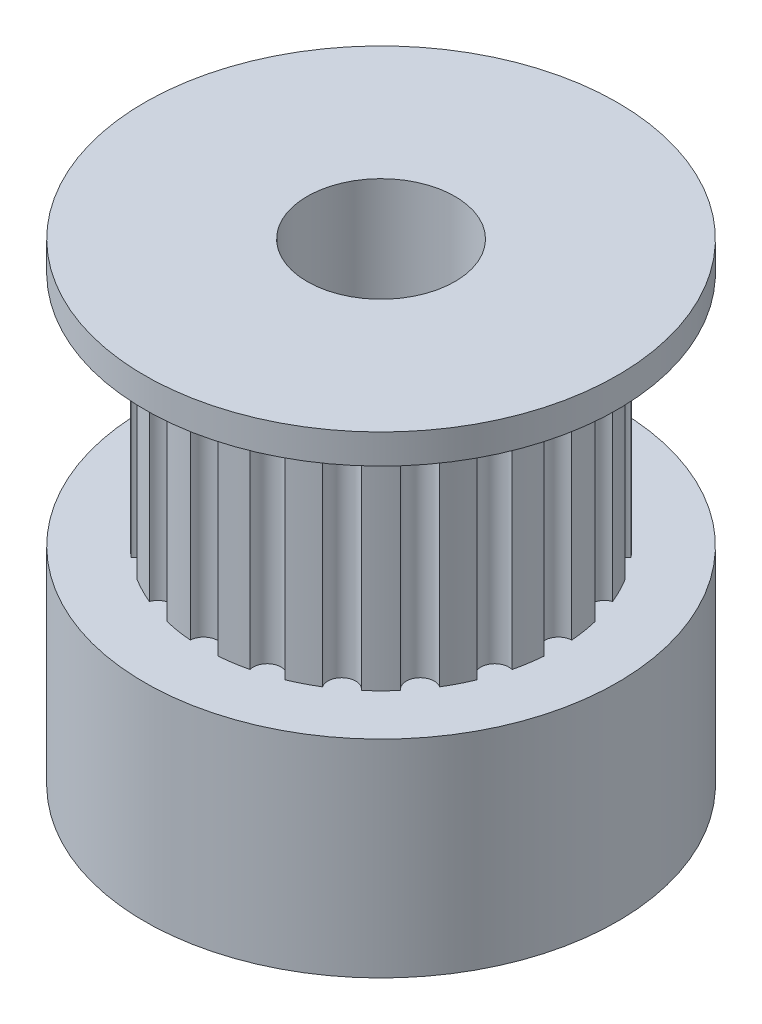
from build123d import *

# Parameters (mm, degrees)
ESQUISSE2_R             = 2.5
ENL_V_MAT_EXTRU_1_DEPTH = 17
ENL_V_MAT_EXTRU_2_DEPTH = 8


with BuildPart() as part:
    # Esquisse1 → Révolution1 (revolve)
    with BuildSketch(Plane.XY):
        Polygon((0, 0), (0, 16), (8, 16), (8, 15), (6, 15), (6, 7), (8, 7), (8, 0), align=None)
    revolve(axis=Axis((0, 0, 0), (0, 1, 0)))

    # Esquisse2 → Enlèv. mat.-Extru.1 (cut, through all)
    with BuildSketch(Plane(origin=(0, 16, 0), x_dir=(1, 0, 0), z_dir=(0, 1, 0))):
        Circle(ESQUISSE2_R)
    extrude(amount=-ENL_V_MAT_EXTRU_1_DEPTH, mode=Mode.SUBTRACT)

    # Esquisse3 → Enlèv. mat.-Extru.2 (cut)
    with BuildSketch(Plane.XZ.offset(-15)):
        with BuildLine():
            ThreePointArc((5.981504002, -0.470754574), (5.528882211, 0), (5.981504002, 0.470754574))
            ThreePointArc((5.981504002, 0.470754574), (6, 0), (5.981504002, -0.470754574))
        make_face()
        with BuildLine():
            ThreePointArc((5.543277195, -2.296100594), (5.706339098, -1.854101966), (5.834219522, -1.400672183))
            ThreePointArc((5.834219522, -1.400672183), (5.258279454, -1.708518563), (5.543277195, -2.296100594))
        make_face()
        with BuildLine():
            ThreePointArc((4.562435794, -3.89668829), (4.472959669, -3.249795425), (5.115840986, -3.134991388))
            ThreePointArc((5.115840986, -3.134991388), (4.854101966, -3.526711514), (4.562435794, -3.89668829))
        make_face()
        with BuildLine():
            ThreePointArc((3.134991388, -5.115840986), (3.249795425, -4.472959669), (3.89668829, -4.562435794))
            ThreePointArc((3.89668829, -4.562435794), (3.526711514, -4.854101966), (3.134991388, -5.115840986))
        make_face()
        with BuildLine():
            ThreePointArc((1.400672183, -5.834219522), (1.708518563, -5.258279454), (2.296100594, -5.543277195))
            ThreePointArc((2.296100594, -5.543277195), (1.854101966, -5.706339098), (1.400672183, -5.834219522))
        make_face()
        with BuildLine():
            ThreePointArc((-0.470754574, -5.981504002), (0, -5.528882211), (0.470754574, -5.981504002))
            ThreePointArc((0.470754574, -5.981504002), (0, -6), (-0.470754574, -5.981504002))
        make_face()
        with BuildLine():
            ThreePointArc((-2.296100594, -5.543277195), (-1.708518563, -5.258279454), (-1.400672183, -5.834219522))
            ThreePointArc((-1.400672183, -5.834219522), (-1.854101966, -5.706339098), (-2.296100594, -5.543277195))
        make_face()
        with BuildLine():
            ThreePointArc((-3.89668829, -4.562435794), (-3.249795425, -4.472959669), (-3.134991388, -5.115840986))
            ThreePointArc((-3.134991388, -5.115840986), (-3.526711514, -4.854101966), (-3.89668829, -4.562435794))
        make_face()
        with BuildLine():
            ThreePointArc((-5.115840986, -3.134991388), (-4.472959669, -3.249795425), (-4.562435794, -3.89668829))
            ThreePointArc((-4.562435794, -3.89668829), (-4.854101966, -3.526711514), (-5.115840986, -3.134991388))
        make_face()
        with BuildLine():
            ThreePointArc((-5.834219522, -1.400672183), (-5.258279454, -1.708518563), (-5.543277195, -2.296100594))
            ThreePointArc((-5.543277195, -2.296100594), (-5.706339098, -1.854101966), (-5.834219522, -1.400672183))
        make_face()
        with BuildLine():
            ThreePointArc((-5.981504002, 0.470754574), (-5.528882211, 0), (-5.981504002, -0.470754574))
            ThreePointArc((-5.981504002, -0.470754574), (-6, 0), (-5.981504002, 0.470754574))
        make_face()
        with BuildLine():
            ThreePointArc((-5.543277195, 2.296100594), (-5.258279454, 1.708518563), (-5.834219522, 1.400672183))
            ThreePointArc((-5.834219522, 1.400672183), (-5.706339098, 1.854101966), (-5.543277195, 2.296100594))
        make_face()
        with BuildLine():
            ThreePointArc((-4.562435794, 3.89668829), (-4.472959669, 3.249795425), (-5.115840986, 3.134991388))
            ThreePointArc((-5.115840986, 3.134991388), (-4.854101966, 3.526711514), (-4.562435794, 3.89668829))
        make_face()
        with BuildLine():
            ThreePointArc((-3.134991388, 5.115840986), (-3.249795425, 4.472959669), (-3.89668829, 4.562435794))
            ThreePointArc((-3.89668829, 4.562435794), (-3.526711514, 4.854101966), (-3.134991388, 5.115840986))
        make_face()
        with BuildLine():
            ThreePointArc((-1.400672183, 5.834219522), (-1.708518563, 5.258279454), (-2.296100594, 5.543277195))
            ThreePointArc((-2.296100594, 5.543277195), (-1.854101966, 5.706339098), (-1.400672183, 5.834219522))
        make_face()
        with BuildLine():
            ThreePointArc((0.470754574, 5.981504002), (0, 5.528882211), (-0.470754574, 5.981504002))
            ThreePointArc((-0.470754574, 5.981504002), (0, 6), (0.470754574, 5.981504002))
        make_face()
        with BuildLine():
            ThreePointArc((2.296100594, 5.543277195), (1.708518563, 5.258279454), (1.400672183, 5.834219522))
            ThreePointArc((1.400672183, 5.834219522), (1.854101966, 5.706339098), (2.296100594, 5.543277195))
        make_face()
        with BuildLine():
            ThreePointArc((3.89668829, 4.562435794), (3.249795425, 4.472959669), (3.134991388, 5.115840986))
            ThreePointArc((3.134991388, 5.115840986), (3.526711514, 4.854101966), (3.89668829, 4.562435794))
        make_face()
        with BuildLine():
            ThreePointArc((5.115840986, 3.134991388), (4.472959669, 3.249795425), (4.562435794, 3.89668829))
            ThreePointArc((4.562435794, 3.89668829), (4.854101966, 3.526711514), (5.115840986, 3.134991388))
        make_face()
        with BuildLine():
            ThreePointArc((5.834219522, 1.400672183), (5.258279454, 1.708518563), (5.543277195, 2.296100594))
            ThreePointArc((5.543277195, 2.296100594), (5.706339098, 1.854101966), (5.834219522, 1.400672183))
        make_face()
    extrude(amount=ENL_V_MAT_EXTRU_2_DEPTH, mode=Mode.SUBTRACT)


solid = part.part
